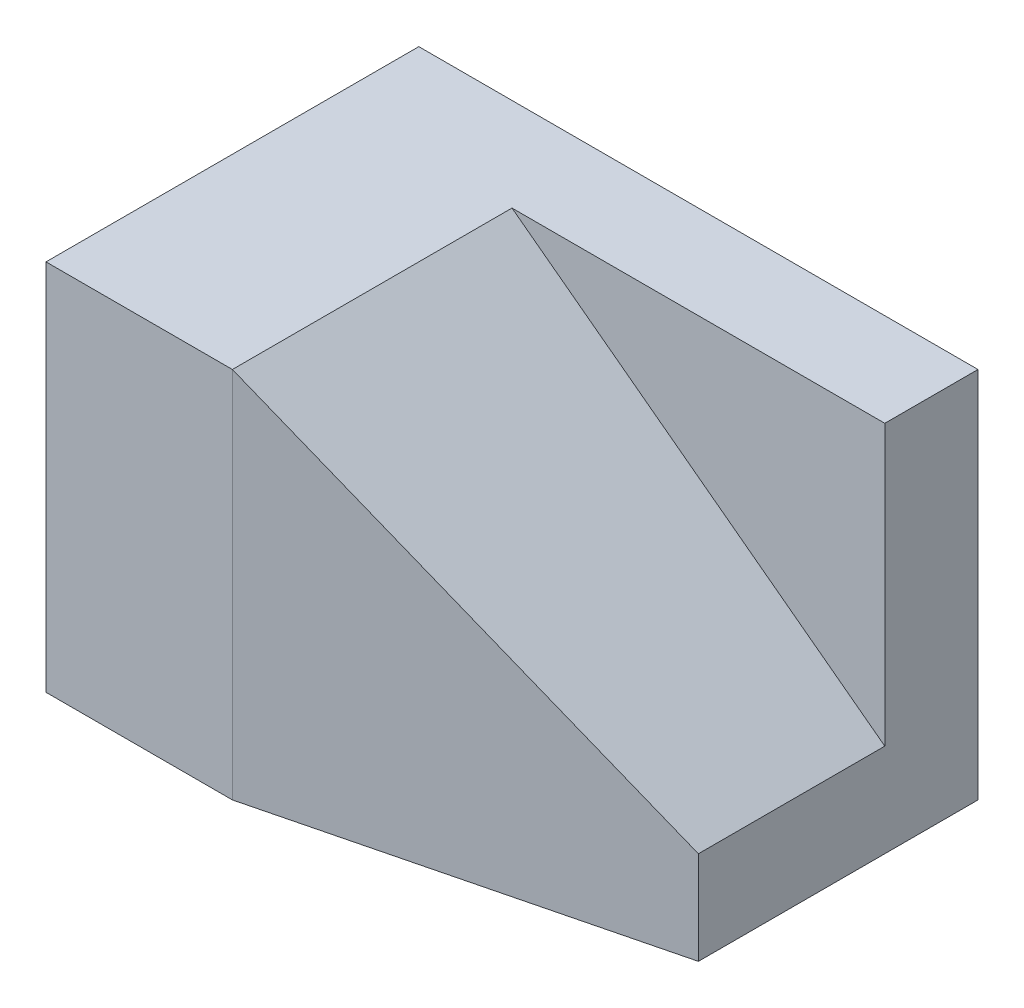
from build123d import *

# Parameters (mm, degrees)
EXTRUDE_1_DEPTH     = 20
EXTRUDE_2_DEPTH     = 20
CUT_EXTRUDE_1_DEPTH = 15
SCALE_1_SCALE       = 0.2


with BuildPart() as part:
    # 草圖1 → 填料-伸長1 (new body)
    with BuildSketch(Plane(origin=(0, 0, 0), x_dir=(1, 0, 0), z_dir=(0, 1, 0))):
        Polygon((-5, 5), (-5, -10), (15, -5), (15, 5), align=None)
    extrude(amount=EXTRUDE_1_DEPTH)

    # 草圖1<3> → 填料-伸長2 (add)
    with BuildSketch(Plane(origin=(0, 0, 0), x_dir=(1, 0, 0), z_dir=(0, 1, 0))):
        Polygon((-15, -10), (-5, -10), (-5, 5), (15, 5), (15, 10), (-15, 10), align=None)
    extrude(amount=EXTRUDE_2_DEPTH)

    # 草圖2 → 除料-伸長1 (cut)
    with BuildSketch(Plane.XY.offset(10)):
        Polygon((-5, 20), (15, 5), (15, 20), align=None)
    extrude(amount=-CUT_EXTRUDE_1_DEPTH, mode=Mode.SUBTRACT)


with BuildPart() as part_1:
    # 縮放比例1: scaled about (-2.387387387, 9.02027027, -1.06981982)
    add(part.part.scale(SCALE_1_SCALE).moved(Location((-1.90990991, 7.216216216, -0.855855856))))


solid = part_1.part
